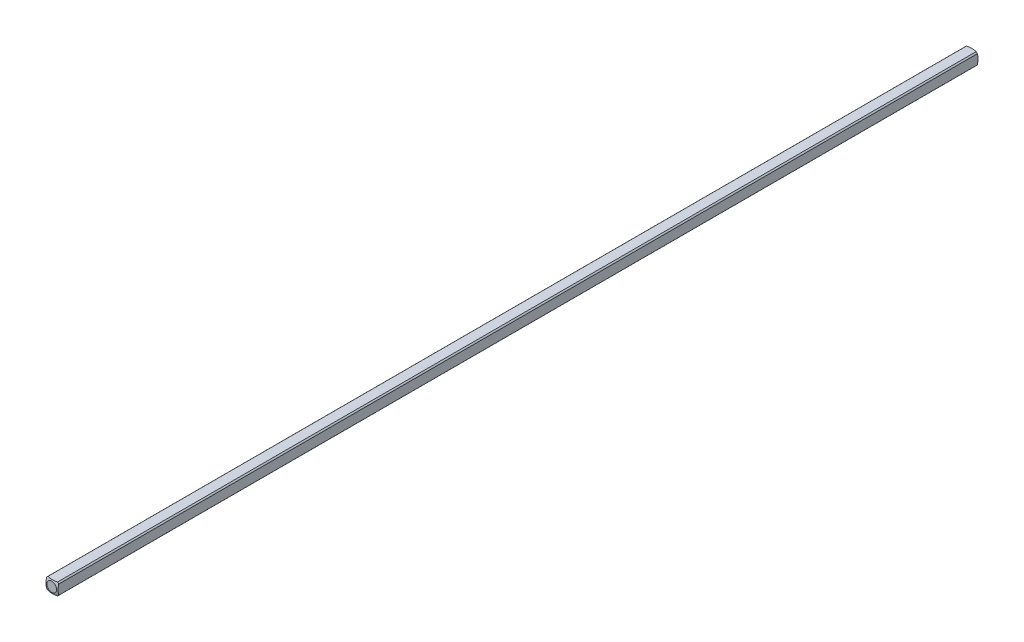
from build123d import *

# Parameters (mm, degrees)
SKETCH1_W           = 3.175
SKETCH1_H           = 3.175
BOSS_EXTRUDE1_DEPTH = 120.65
SKETCH2_OUTSIDE_W   = 29.322
SKETCH2_OUTSIDE_H   = 29.322
SKETCH2_OUTSIDE_R   = 2.032
CUT_EXTRUDE1_DEPTH  = 121.65


with BuildPart() as part:
    # Sketch1 → Boss-Extrude1 (new body)
    with BuildSketch(Plane.XY):
        Rectangle(SKETCH1_W, SKETCH1_H)
    extrude(amount=BOSS_EXTRUDE1_DEPTH)

    # Sketch2 outside → Cut-Extrude1 (cut, through all)
    with BuildSketch(Plane(origin=(0, 0, 0), x_dir=(-1, 0, 0), z_dir=(0, 0, -1))):
        Rectangle(SKETCH2_OUTSIDE_W, SKETCH2_OUTSIDE_H)
        Circle(SKETCH2_OUTSIDE_R, mode=Mode.SUBTRACT)
    extrude(amount=-CUT_EXTRUDE1_DEPTH, mode=Mode.SUBTRACT)

    # Sketch3 → Cut-Revolve1 (revolve, cut)
    with BuildSketch(Plane(origin=(0, 0, 0), x_dir=(1, 0, 0), z_dir=(0, 1, 0))):
        with BuildLine():
            Line((-5.053685963, -4.40273269), (-5.053685963, 5.740530545))
            Line((-5.053685963, 5.740530545), (0, 5.740530545))
            Line((0, 5.740530545), (0, 0.160877736))
            ThreePointArc((0, 0.160877736), (-3.404639553, -1.148866368), (-5.053685963, -4.40273269))
        make_face()
    revolve(axis=Axis((0, 0, 120.65), (0, 0, -1)), mode=Mode.SUBTRACT)

    # Mirror1: part across plane


with BuildPart() as part_1:
    add(part.part)
    add(part.part.mirror(Plane(origin=(0, 0, 120.65), x_dir=(1, 0, 0), z_dir=(0, 0, -1))))


solid = part_1.part
